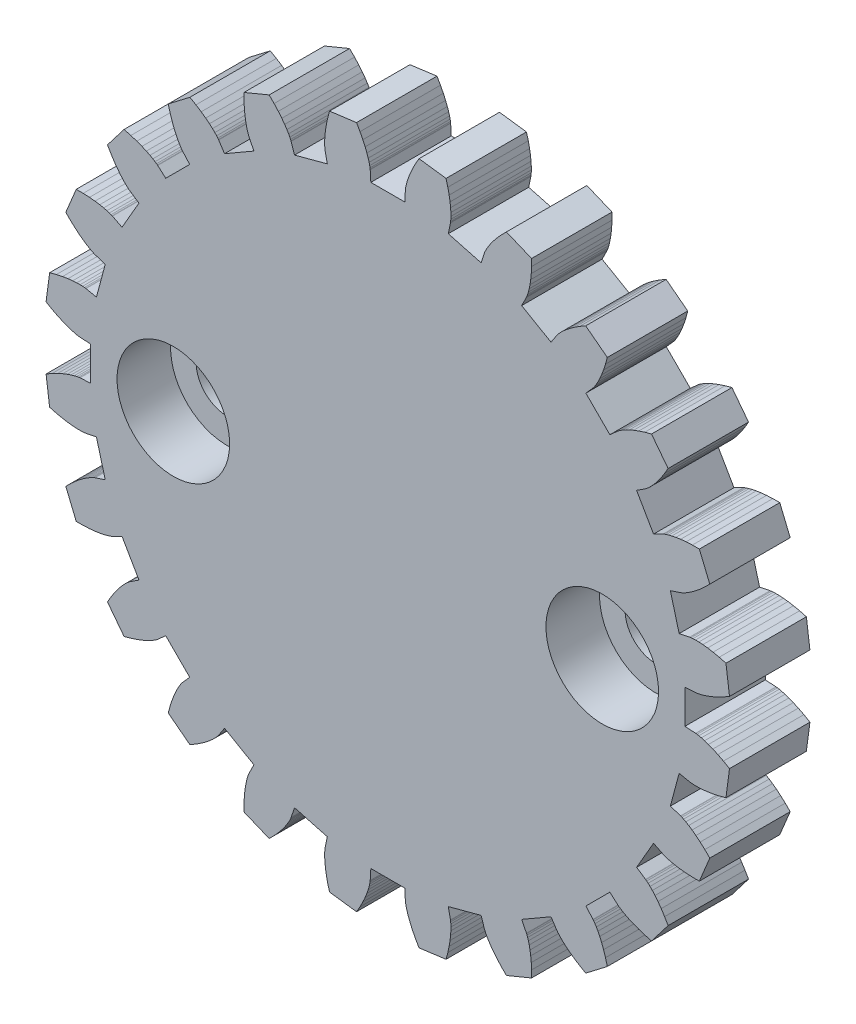
from build123d import *

# Parameters (mm, degrees)
MAIN_GEAR_BODY_DEPTH      = 3
SKETCH1_R                 = 4.075
SKETCH1_R_2               = 1.15
SERVO_CLEARANCE_DEPTH     = 4
SKETCH2_R                 = 2.1
BOLT_HEAD_CLEARANCE_DEPTH = 2
SKETCH4_R                 = 4.075
BOSS_EXTRUDE2_DEPTH       = 1


with BuildPart() as part:
    # Model → Main Gear Body (new body)
    with BuildSketch(Plane.XY):
        Polygon((11.481280763, -0.655890262), (11.081931867, -0.633076687), (11.081931867, 0.633076687), (11.481280763, 0.655890262), (11.494959484, 0.657119822), (11.535795525, 0.662587053), (11.603342457, 0.674939875), (11.696960474, 0.69678954), (11.81581907, 0.730698092), (11.958900465, 0.779166001), (12.125003794, 0.844620031), (12.312750022, 0.929401369), (12.520587586, 1.035754071), (12.746798737, 1.165813859), (12.614196933, 2.173024562), (12.36203179, 2.240104916), (12.133750014, 2.289041418), (11.930458058, 2.322341602), (11.753073814, 2.342574636), (11.602323381, 2.352358851), (11.478738615, 2.354349128), (11.382655444, 2.351224158), (11.314212973, 2.345673635), (11.273353363, 2.34038543), (11.259822499, 2.338032781), (10.868176499, 2.256709902), (10.540471892, 3.479720146), (10.920308717, 3.605115467), (10.933203113, 3.609843444), (10.971232676, 3.625693529), (11.033280856, 3.655107871), (11.118053808, 3.700443153), (11.224086216, 3.763959167), (11.349747813, 3.847807762), (11.493250558, 3.954022205), (11.652656464, 4.084506989), (11.82588603, 4.24102813), (12.010727273, 4.425203993), (11.621958453, 5.36377495), (11.361023956, 5.363304455), (11.127854994, 5.351489815), (10.922871322, 5.331039494), (10.746294605, 5.304672682), (10.598148527, 5.275106425), (10.478259688, 5.245042794), (10.386259274, 5.21715615), (10.321585504, 5.194080542), (10.28348684, 5.178397283), (10.27102594, 5.172622753), (9.913772864, 4.99270544), (9.280696176, 6.089226427), (9.615135678, 6.30865801), (9.626367017, 6.316562201), (9.658998451, 6.341714983), (9.711319399, 6.386186306), (9.781470148, 6.45191768), (9.867450435, 6.540712645), (9.967128604, 6.654227783), (10.078251291, 6.7939643), (10.198453625, 6.961260207), (10.325269884, 7.157283131), (10.456144594, 7.383023787), (9.837702711, 8.18899294), (9.585781114, 8.121003659), (9.363615046, 8.049243025), (9.170908956, 7.976435853), (9.007173178, 7.905266052), (8.871727365, 7.838364214), (8.76370468, 7.778295462), (8.682056698, 7.727547573), (8.625559041, 7.688519444), (8.592817683, 7.663509918), (8.582275936, 7.654707033), (8.28376199, 7.388456353), (7.388456353, 8.28376199), (7.654707033, 8.582275936), (7.663509918, 8.592817683), (7.688519444, 8.625559041), (7.727547573, 8.682056698), (7.778295462, 8.76370468), (7.838364214, 8.871727365), (7.905266052, 9.007173178), (7.976435853, 9.170908956), (8.049243025, 9.363615046), (8.121003659, 9.585781114), (8.18899294, 9.837702711), (7.383023787, 10.456144594), (7.157283131, 10.325269884), (6.961260207, 10.198453625), (6.7939643, 10.078251291), (6.654227783, 9.967128604), (6.540712645, 9.867450435), (6.45191768, 9.781470148), (6.386186306, 9.711319399), (6.341714983, 9.658998451), (6.316562201, 9.626367017), (6.30865801, 9.615135678), (6.089226427, 9.280696176), (4.99270544, 9.913772864), (5.172622753, 10.27102594), (5.178397283, 10.28348684), (5.194080542, 10.321585504), (5.21715615, 10.386259274), (5.245042794, 10.478259688), (5.275106425, 10.598148527), (5.304672682, 10.746294605), (5.331039494, 10.922871322), (5.351489815, 11.127854994), (5.363304455, 11.361023956), (5.36377495, 11.621958453), (4.425203993, 12.010727273), (4.24102813, 11.82588603), (4.084506989, 11.652656464), (3.954022205, 11.493250558), (3.847807762, 11.349747813), (3.763959167, 11.224086216), (3.700443153, 11.118053808), (3.655107871, 11.033280856), (3.625693529, 10.971232676), (3.609843444, 10.933203113), (3.605115467, 10.920308717), (3.479720146, 10.540471892), (2.256709902, 10.868176499), (2.338032781, 11.259822499), (2.34038543, 11.273353363), (2.345673635, 11.314212973), (2.351224158, 11.382655444), (2.354349128, 11.478738615), (2.352358851, 11.602323381), (2.342574636, 11.753073814), (2.322341602, 11.930458058), (2.289041418, 12.133750014), (2.240104916, 12.36203179), (2.173024562, 12.614196933), (1.165813859, 12.746798737), (1.035754071, 12.520587586), (0.929401369, 12.312750022), (0.844620031, 12.125003794), (0.779166001, 11.958900465), (0.730698092, 11.81581907), (0.69678954, 11.696960474), (0.674939875, 11.603342457), (0.662587053, 11.535795525), (0.657119822, 11.494959484), (0.655890262, 11.481280763), (0.633076687, 11.081931867), (-0.633076687, 11.081931867), (-0.655890262, 11.481280763), (-0.657119822, 11.494959484), (-0.662587053, 11.535795525), (-0.674939875, 11.603342457), (-0.69678954, 11.696960474), (-0.730698092, 11.81581907), (-0.779166001, 11.958900465), (-0.844620031, 12.125003794), (-0.929401369, 12.312750022), (-1.035754071, 12.520587586), (-1.165813859, 12.746798737), (-2.173024562, 12.614196933), (-2.240104916, 12.36203179), (-2.289041418, 12.133750014), (-2.322341602, 11.930458058), (-2.342574636, 11.753073814), (-2.352358851, 11.602323381), (-2.354349128, 11.478738615), (-2.351224158, 11.382655444), (-2.345673635, 11.314212973), (-2.34038543, 11.273353363), (-2.338032781, 11.259822499), (-2.256709902, 10.868176499), (-3.479720146, 10.540471892), (-3.605115467, 10.920308717), (-3.609843444, 10.933203113), (-3.625693529, 10.971232676), (-3.655107871, 11.033280856), (-3.700443153, 11.118053808), (-3.763959167, 11.224086216), (-3.847807762, 11.349747813), (-3.954022205, 11.493250558), (-4.084506989, 11.652656464), (-4.24102813, 11.82588603), (-4.425203993, 12.010727273), (-5.36377495, 11.621958453), (-5.363304455, 11.361023956), (-5.351489815, 11.127854994), (-5.331039494, 10.922871322), (-5.304672682, 10.746294605), (-5.275106425, 10.598148527), (-5.245042794, 10.478259688), (-5.21715615, 10.386259274), (-5.194080542, 10.321585504), (-5.178397283, 10.28348684), (-5.172622753, 10.27102594), (-4.99270544, 9.913772864), (-6.089226427, 9.280696176), (-6.30865801, 9.615135678), (-6.316562201, 9.626367017), (-6.341714983, 9.658998451), (-6.386186306, 9.711319399), (-6.45191768, 9.781470148), (-6.540712645, 9.867450435), (-6.654227783, 9.967128604), (-6.7939643, 10.078251291), (-6.961260207, 10.198453625), (-7.157283131, 10.325269884), (-7.383023787, 10.456144594), (-8.18899294, 9.837702711), (-8.121003659, 9.585781114), (-8.049243025, 9.363615046), (-7.976435853, 9.170908956), (-7.905266052, 9.007173178), (-7.838364214, 8.871727365), (-7.778295462, 8.76370468), (-7.727547573, 8.682056698), (-7.688519444, 8.625559041), (-7.663509918, 8.592817683), (-7.654707033, 8.582275936), (-7.388456353, 8.28376199), (-8.28376199, 7.388456353), (-8.582275936, 7.654707033), (-8.592817683, 7.663509918), (-8.625559041, 7.688519444), (-8.682056698, 7.727547573), (-8.76370468, 7.778295462), (-8.871727365, 7.838364214), (-9.007173178, 7.905266052), (-9.170908956, 7.976435853), (-9.363615046, 8.049243025), (-9.585781114, 8.121003659), (-9.837702711, 8.18899294), (-10.456144594, 7.383023787), (-10.325269884, 7.157283131), (-10.198453625, 6.961260207), (-10.078251291, 6.7939643), (-9.967128604, 6.654227783), (-9.867450435, 6.540712645), (-9.781470148, 6.45191768), (-9.711319399, 6.386186306), (-9.658998451, 6.341714983), (-9.626367017, 6.316562201), (-9.615135678, 6.30865801), (-9.280696176, 6.089226427), (-9.913772864, 4.99270544), (-10.27102594, 5.172622753), (-10.28348684, 5.178397283), (-10.321585504, 5.194080542), (-10.386259274, 5.21715615), (-10.478259688, 5.245042794), (-10.598148527, 5.275106425), (-10.746294605, 5.304672682), (-10.922871322, 5.331039494), (-11.127854994, 5.351489815), (-11.361023956, 5.363304455), (-11.621958453, 5.36377495), (-12.010727273, 4.425203993), (-11.82588603, 4.24102813), (-11.652656464, 4.084506989), (-11.493250558, 3.954022205), (-11.349747813, 3.847807762), (-11.224086216, 3.763959167), (-11.118053808, 3.700443153), (-11.033280856, 3.655107871), (-10.971232676, 3.625693529), (-10.933203113, 3.609843444), (-10.920308717, 3.605115467), (-10.540471892, 3.479720146), (-10.868176499, 2.256709902), (-11.259822499, 2.338032781), (-11.273353363, 2.34038543), (-11.314212973, 2.345673635), (-11.382655444, 2.351224158), (-11.478738615, 2.354349128), (-11.602323381, 2.352358851), (-11.753073814, 2.342574636), (-11.930458058, 2.322341602), (-12.133750014, 2.289041418), (-12.36203179, 2.240104916), (-12.614196933, 2.173024562), (-12.746798737, 1.165813859), (-12.520587586, 1.035754071), (-12.312750022, 0.929401369), (-12.125003794, 0.844620031), (-11.958900465, 0.779166001), (-11.81581907, 0.730698092), (-11.696960474, 0.69678954), (-11.603342457, 0.674939875), (-11.535795525, 0.662587053), (-11.494959484, 0.657119822), (-11.481280763, 0.655890262), (-11.081931867, 0.633076687), (-11.081931867, -0.633076687), (-11.481280763, -0.655890262), (-11.494959484, -0.657119822), (-11.535795525, -0.662587053), (-11.603342457, -0.674939875), (-11.696960474, -0.69678954), (-11.81581907, -0.730698092), (-11.958900465, -0.779166001), (-12.125003794, -0.844620031), (-12.312750022, -0.929401369), (-12.520587586, -1.035754071), (-12.746798737, -1.165813859), (-12.614196933, -2.173024562), (-12.36203179, -2.240104916), (-12.133750014, -2.289041418), (-11.930458058, -2.322341602), (-11.753073814, -2.342574636), (-11.602323381, -2.352358851), (-11.478738615, -2.354349128), (-11.382655444, -2.351224158), (-11.314212973, -2.345673635), (-11.273353363, -2.34038543), (-11.259822499, -2.338032781), (-10.868176499, -2.256709902), (-10.540471892, -3.479720146), (-10.920308717, -3.605115467), (-10.933203113, -3.609843444), (-10.971232676, -3.625693529), (-11.033280856, -3.655107871), (-11.118053808, -3.700443153), (-11.224086216, -3.763959167), (-11.349747813, -3.847807762), (-11.493250558, -3.954022205), (-11.652656464, -4.084506989), (-11.82588603, -4.24102813), (-12.010727273, -4.425203993), (-11.621958453, -5.36377495), (-11.361023956, -5.363304455), (-11.127854994, -5.351489815), (-10.922871322, -5.331039494), (-10.746294605, -5.304672682), (-10.598148527, -5.275106425), (-10.478259688, -5.245042794), (-10.386259274, -5.21715615), (-10.321585504, -5.194080542), (-10.28348684, -5.178397283), (-10.27102594, -5.172622753), (-9.913772864, -4.99270544), (-9.280696176, -6.089226427), (-9.615135678, -6.30865801), (-9.626367017, -6.316562201), (-9.658998451, -6.341714983), (-9.711319399, -6.386186306), (-9.781470148, -6.45191768), (-9.867450435, -6.540712645), (-9.967128604, -6.654227783), (-10.078251291, -6.7939643), (-10.198453625, -6.961260207), (-10.325269884, -7.157283131), (-10.456144594, -7.383023787), (-9.837702711, -8.18899294), (-9.585781114, -8.121003659), (-9.363615046, -8.049243025), (-9.170908956, -7.976435853), (-9.007173178, -7.905266052), (-8.871727365, -7.838364214), (-8.76370468, -7.778295462), (-8.682056698, -7.727547573), (-8.625559041, -7.688519444), (-8.592817683, -7.663509918), (-8.582275936, -7.654707033), (-8.28376199, -7.388456353), (-7.388456353, -8.28376199), (-7.654707033, -8.582275936), (-7.663509918, -8.592817683), (-7.688519444, -8.625559041), (-7.727547573, -8.682056698), (-7.778295462, -8.76370468), (-7.838364214, -8.871727365), (-7.905266052, -9.007173178), (-7.976435853, -9.170908956), (-8.049243025, -9.363615046), (-8.121003659, -9.585781114), (-8.18899294, -9.837702711), (-7.383023787, -10.456144594), (-7.157283131, -10.325269884), (-6.961260207, -10.198453625), (-6.7939643, -10.078251291), (-6.654227783, -9.967128604), (-6.540712645, -9.867450435), (-6.45191768, -9.781470148), (-6.386186306, -9.711319399), (-6.341714983, -9.658998451), (-6.316562201, -9.626367017), (-6.30865801, -9.615135678), (-6.089226427, -9.280696176), (-4.99270544, -9.913772864), (-5.172622753, -10.27102594), (-5.178397283, -10.28348684), (-5.194080542, -10.321585504), (-5.21715615, -10.386259274), (-5.245042794, -10.478259688), (-5.275106425, -10.598148527), (-5.304672682, -10.746294605), (-5.331039494, -10.922871322), (-5.351489815, -11.127854994), (-5.363304455, -11.361023956), (-5.36377495, -11.621958453), (-4.425203993, -12.010727273), (-4.24102813, -11.82588603), (-4.084506989, -11.652656464), (-3.954022205, -11.493250558), (-3.847807762, -11.349747813), (-3.763959167, -11.224086216), (-3.700443153, -11.118053808), (-3.655107871, -11.033280856), (-3.625693529, -10.971232676), (-3.609843444, -10.933203113), (-3.605115467, -10.920308717), (-3.479720146, -10.540471892), (-2.256709902, -10.868176499), (-2.338032781, -11.259822499), (-2.34038543, -11.273353363), (-2.345673635, -11.314212973), (-2.351224158, -11.382655444), (-2.354349128, -11.478738615), (-2.352358851, -11.602323381), (-2.342574636, -11.753073814), (-2.322341602, -11.930458058), (-2.289041418, -12.133750014), (-2.240104916, -12.36203179), (-2.173024562, -12.614196933), (-1.165813859, -12.746798737), (-1.035754071, -12.520587586), (-0.929401369, -12.312750022), (-0.844620031, -12.125003794), (-0.779166001, -11.958900465), (-0.730698092, -11.81581907), (-0.69678954, -11.696960474), (-0.674939875, -11.603342457), (-0.662587053, -11.535795525), (-0.657119822, -11.494959484), (-0.655890262, -11.481280763), (-0.633076687, -11.081931867), (0.633076687, -11.081931867), (0.655890262, -11.481280763), (0.657119822, -11.494959484), (0.662587053, -11.535795525), (0.674939875, -11.603342457), (0.69678954, -11.696960474), (0.730698092, -11.81581907), (0.779166001, -11.958900465), (0.844620031, -12.125003794), (0.929401369, -12.312750022), (1.035754071, -12.520587586), (1.165813859, -12.746798737), (2.173024562, -12.614196933), (2.240104916, -12.36203179), (2.289041418, -12.133750014), (2.322341602, -11.930458058), (2.342574636, -11.753073814), (2.352358851, -11.602323381), (2.354349128, -11.478738615), (2.351224158, -11.382655444), (2.345673635, -11.314212973), (2.34038543, -11.273353363), (2.338032781, -11.259822499), (2.256709902, -10.868176499), (3.479720146, -10.540471892), (3.605115467, -10.920308717), (3.609843444, -10.933203113), (3.625693529, -10.971232676), (3.655107871, -11.033280856), (3.700443153, -11.118053808), (3.763959167, -11.224086216), (3.847807762, -11.349747813), (3.954022205, -11.493250558), (4.084506989, -11.652656464), (4.24102813, -11.82588603), (4.425203993, -12.010727273), (5.36377495, -11.621958453), (5.363304455, -11.361023956), (5.351489815, -11.127854994), (5.331039494, -10.922871322), (5.304672682, -10.746294605), (5.275106425, -10.598148527), (5.245042794, -10.478259688), (5.21715615, -10.386259274), (5.194080542, -10.321585504), (5.178397283, -10.28348684), (5.172622753, -10.27102594), (4.99270544, -9.913772864), (6.089226427, -9.280696176), (6.30865801, -9.615135678), (6.316562201, -9.626367017), (6.341714983, -9.658998451), (6.386186306, -9.711319399), (6.45191768, -9.781470148), (6.540712645, -9.867450435), (6.654227783, -9.967128604), (6.7939643, -10.078251291), (6.961260207, -10.198453625), (7.157283131, -10.325269884), (7.383023787, -10.456144594), (8.18899294, -9.837702711), (8.121003659, -9.585781114), (8.049243025, -9.363615046), (7.976435853, -9.170908956), (7.905266052, -9.007173178), (7.838364214, -8.871727365), (7.778295462, -8.76370468), (7.727547573, -8.682056698), (7.688519444, -8.625559041), (7.663509918, -8.592817683), (7.654707033, -8.582275936), (7.388456353, -8.28376199), (8.28376199, -7.388456353), (8.582275936, -7.654707033), (8.592817683, -7.663509918), (8.625559041, -7.688519444), (8.682056698, -7.727547573), (8.76370468, -7.778295462), (8.871727365, -7.838364214), (9.007173178, -7.905266052), (9.170908956, -7.976435853), (9.363615046, -8.049243025), (9.585781114, -8.121003659), (9.837702711, -8.18899294), (10.456144594, -7.383023787), (10.325269884, -7.157283131), (10.198453625, -6.961260207), (10.078251291, -6.7939643), (9.967128604, -6.654227783), (9.867450435, -6.540712645), (9.781470148, -6.45191768), (9.711319399, -6.386186306), (9.658998451, -6.341714983), (9.626367017, -6.316562201), (9.615135678, -6.30865801), (9.280696176, -6.089226427), (9.913772864, -4.99270544), (10.27102594, -5.172622753), (10.28348684, -5.178397283), (10.321585504, -5.194080542), (10.386259274, -5.21715615), (10.478259688, -5.245042794), (10.598148527, -5.275106425), (10.746294605, -5.304672682), (10.922871322, -5.331039494), (11.127854994, -5.351489815), (11.361023956, -5.363304455), (11.621958453, -5.36377495), (12.010727273, -4.425203993), (11.82588603, -4.24102813), (11.652656464, -4.084506989), (11.493250558, -3.954022205), (11.349747813, -3.847807762), (11.224086216, -3.763959167), (11.118053808, -3.700443153), (11.033280856, -3.655107871), (10.971232676, -3.625693529), (10.933203113, -3.609843444), (10.920308717, -3.605115467), (10.540471892, -3.479720146), (10.868176499, -2.256709902), (11.259822499, -2.338032781), (11.273353363, -2.34038543), (11.314212973, -2.345673635), (11.382655444, -2.351224158), (11.478738615, -2.354349128), (11.602323381, -2.352358851), (11.753073814, -2.342574636), (11.930458058, -2.322341602), (12.133750014, -2.289041418), (12.36203179, -2.240104916), (12.614196933, -2.173024562), (12.746798737, -1.165813859), (12.520587586, -1.035754071), (12.312750022, -0.929401369), (12.125003794, -0.844620031), (11.958900465, -0.779166001), (11.81581907, -0.730698092), (11.696960474, -0.69678954), (11.603342457, -0.674939875), (11.535795525, -0.662587053), (11.494959484, -0.657119822), align=None)
    extrude(amount=MAIN_GEAR_BODY_DEPTH)

    # Sketch1 → Servo Clearance (cut, through all)
    with BuildSketch(Plane.XY.offset(3)):
        Circle(SKETCH1_R)
        with Locations((-8, 0)):
            Circle(SKETCH1_R_2)
        with Locations((8, 0)):
            Circle(SKETCH1_R_2)
    extrude(amount=-SERVO_CLEARANCE_DEPTH, mode=Mode.SUBTRACT)

    # Sketch2 → Bolt Head Clearance (cut)
    with BuildSketch(Plane.XY.offset(3)):
        with Locations((8, 0)):
            Circle(SKETCH2_R)
        with Locations((-8, 0)):
            Circle(SKETCH2_R)
    extrude(amount=-BOLT_HEAD_CLEARANCE_DEPTH, mode=Mode.SUBTRACT)

    # Sketch4 → Boss-Extrude2 (add)
    with BuildSketch(Plane.XY.offset(3)):
        Circle(SKETCH4_R)
    extrude(amount=-BOSS_EXTRUDE2_DEPTH)


solid = part.part
